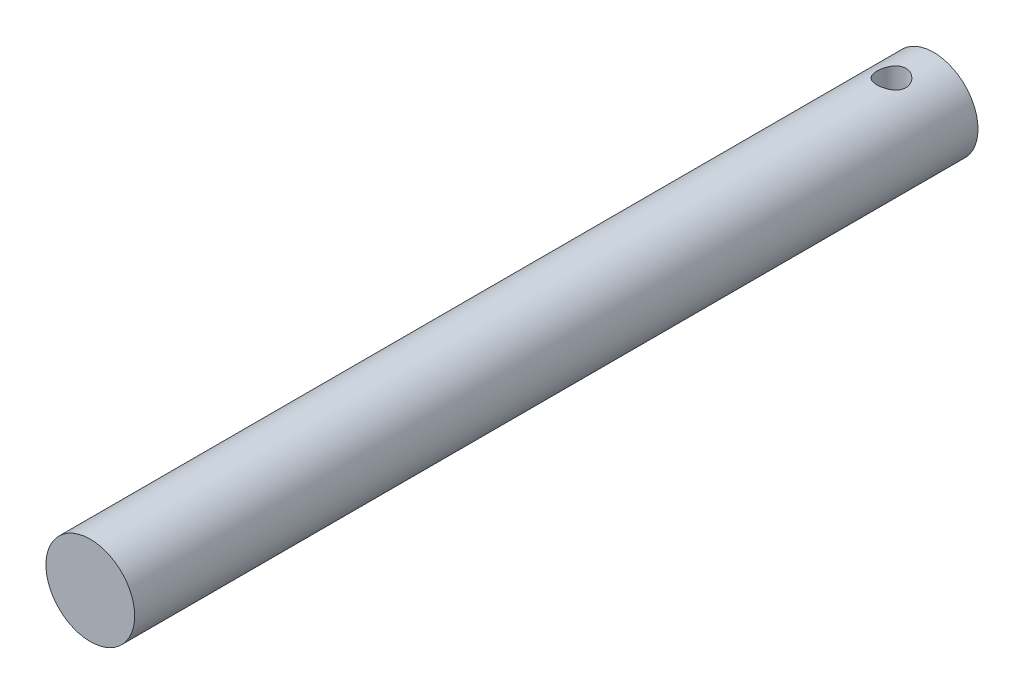
from build123d import *

# Parameters (mm, degrees)
SKETCH_1_R          = 10
EXTRUDE_1_DEPTH     = 190
SKETCH_2_R          = 3.25
CUT_EXTRUDE_1_DEPTH = 210


with BuildPart() as part:
    # 草图1 → 凸台-拉伸1 (new body)
    with BuildSketch(Plane.XY):
        Circle(SKETCH_1_R)
    extrude(amount=EXTRUDE_1_DEPTH)

    # 草图2 → 切除-拉伸1 (cut, symmetric)
    with BuildSketch(Plane(origin=(0, 0, 0), x_dir=(1, 0, 0), z_dir=(0, 1, 0))):
        with Locations((0, -9.5)):
            Circle(SKETCH_2_R)
    extrude(amount=CUT_EXTRUDE_1_DEPTH, both=True, mode=Mode.SUBTRACT)


solid = part.part
